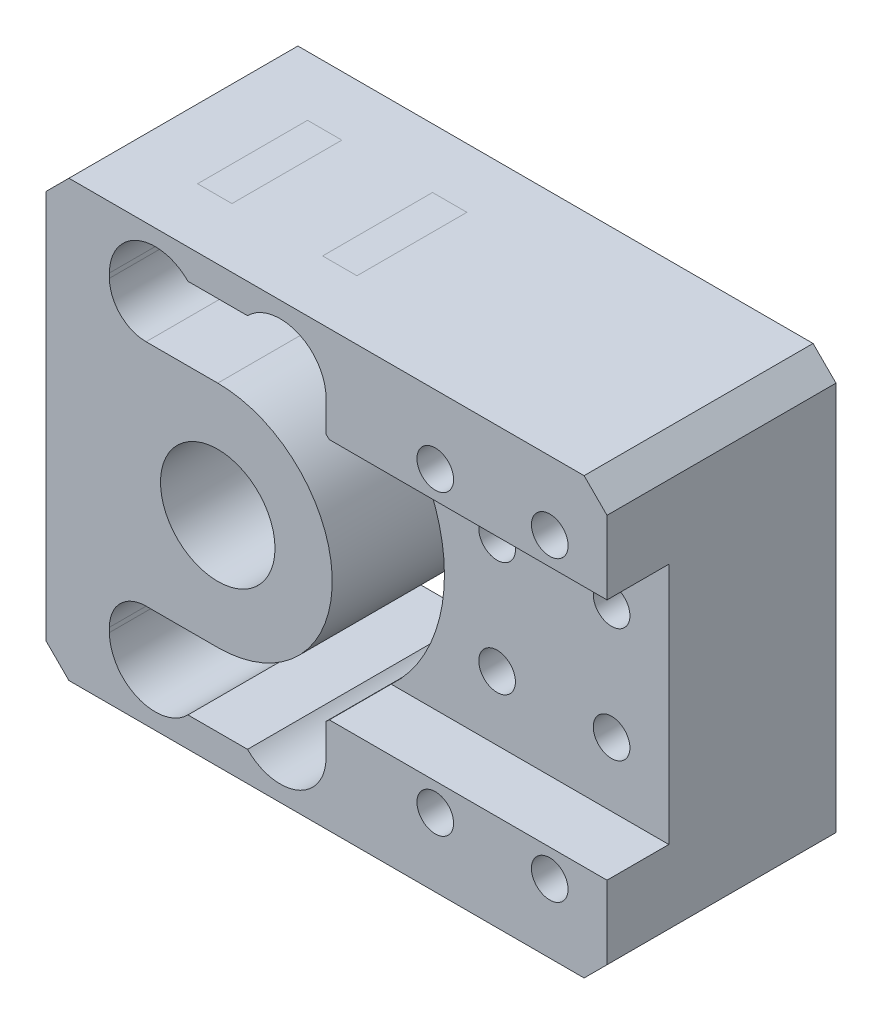
from build123d import *

# Parameters (mm, degrees)
SKETCH1_W                = 15
SKETCH1_H                = 19
BOSS_EXTRUDE1_DEPTH      = 5
BOSS_EXTRUDE1_DEPTH_BACK = 5
CUT_EXTRUDE1_START       = -6
SKETCH2_R                = 2
CUT_EXTRUDE1_DEPTH       = 16
SKETCH5_R                = 2
CUT_EXTRUDE4_DEPTH       = 17
CUT_EXTRUDE4_DEPTH_BACK  = 17
SKETCH6_R                = 2
CUT_EXTRUDE5_DEPTH       = 17
CUT_EXTRUDE5_DEPTH_BACK  = 17
SKETCH10_W               = 9.46
SKETCH10_H               = 13.6
CUT_EXTRUDE6_DEPTH       = 6
CUT_EXTRUDE6_DEPTH_BACK  = 6
BOSS_EXTRUDE2_START      = -5
SKETCH7_R                = 5
SKETCH7_R_2              = 2.5
BOSS_EXTRUDE2_DEPTH      = 10
BOSS_EXTRUDE3_DEPTH      = 5
FILLET1_R                = 1.6
SKETCH11_W               = 12.27
SKETCH11_H               = 19
BOSS_EXTRUDE4_DEPTH      = 10
CHAMFER1_SIZE            = 1
SKETCH16_W               = 5.80562201
SKETCH16_H               = 3.2
CUT_EXTRUDE8_DEPTH       = 11.5
CUT_EXTRUDE9_DEPTH       = 11.5
CUT_EXTRUDE10_DEPTH      = 2.7
TROU_TARAUD_M21_D        = 1.6
TROU_TARAUD_M2_51_D      = 2.05
TROU_TARAUD_M2_51_DEPTH  = 8.25
TROU_TARAUD_M2_51_TIP    = 0.615882135


with BuildPart() as part:
    # Sketch1 → Boss-Extrude1 (new body, two sides)
    with BuildSketch(Plane.XY) as boss_extrude1_sk:
        Rectangle(SKETCH1_W, SKETCH1_H)
    extrude(amount=BOSS_EXTRUDE1_DEPTH)
    extrude(boss_extrude1_sk.sketch, amount=-BOSS_EXTRUDE1_DEPTH_BACK)

    # Sketch2 → Cut-Extrude1 (cut)
    with BuildSketch(Plane.XY.offset(CUT_EXTRUDE1_START)):
        with Locations((-2.73, 6.8)):
            Circle(SKETCH2_R)
    cut_extrude1 = extrude(amount=CUT_EXTRUDE1_DEPTH, mode=Mode.SUBTRACT)

    # Mirror3: Cut-Extrude1 across plane
    add(cut_extrude1.mirror(Plane.ZX), mode=Mode.SUBTRACT)

    # Sketch5 → Cut-Extrude4 (cut, two sides)
    with BuildSketch(Plane.XY) as cut_extrude4_sk:
        with Locations((2.73, 6.8)):
            Circle(SKETCH5_R)
    extrude(amount=CUT_EXTRUDE4_DEPTH, mode=Mode.SUBTRACT)
    extrude(cut_extrude4_sk.sketch, amount=-CUT_EXTRUDE4_DEPTH_BACK, mode=Mode.SUBTRACT)

    # Sketch6 → Cut-Extrude5 (cut, two sides)
    with BuildSketch(Plane.XY) as cut_extrude5_sk:
        with Locations((2.73, -6.8)):
            Circle(SKETCH6_R)
    extrude(amount=CUT_EXTRUDE5_DEPTH, mode=Mode.SUBTRACT)
    extrude(cut_extrude5_sk.sketch, amount=-CUT_EXTRUDE5_DEPTH_BACK, mode=Mode.SUBTRACT)

    # Sketch10 → Cut-Extrude6 (cut, two sides)
    with BuildSketch(Plane.XY) as cut_extrude6_sk:
        Rectangle(SKETCH10_W, SKETCH10_H)
    extrude(amount=CUT_EXTRUDE6_DEPTH, mode=Mode.SUBTRACT)
    extrude(cut_extrude6_sk.sketch, amount=-CUT_EXTRUDE6_DEPTH_BACK, mode=Mode.SUBTRACT)



with BuildPart() as body_2:
    # Sketch7 → Boss-Extrude2 (new body)
    with BuildSketch(Plane.XY.offset(BOSS_EXTRUDE2_START)):
        Circle(SKETCH7_R)
        Circle(SKETCH7_R_2, mode=Mode.SUBTRACT)
    extrude(amount=BOSS_EXTRUDE2_DEPTH)


with BuildPart() as part_1:
    add(part.part)

    add(body_2.part)  # Boss-Extrude3 merges body 2
    # Sketch8 → Boss-Extrude3 (add, symmetric)
    with BuildSketch(Plane.XY):
        Polygon((0, 5), (-7.5, 5), (-7.5, 0), (-5, 0), align=None)
    boss_extrude3 = extrude(amount=BOSS_EXTRUDE3_DEPTH, both=True)

    # Mirror7: Boss-Extrude3 across plane
    add(boss_extrude3.mirror(Plane.ZX))

    # Fillet1
    fillet1_edges = [part_1.edges().sort_by_distance(p)[0] for p in [
        (-4.73, -5, 0),
        (-4.73, 5, 0),
    ]]
    fillet(fillet1_edges, radius=FILLET1_R)

    # Sketch11 → Boss-Extrude4 (add)
    with BuildSketch(Plane.XY.offset(5)):
        with Locations((10.865, 0)):
            Rectangle(SKETCH11_W, SKETCH11_H)
    extrude(amount=-BOSS_EXTRUDE4_DEPTH)

    # Chamfer1
    chamfer1_edges = [part_1.edges().sort_by_distance(p)[0] for p in [
        (17, 9.5, 0),
        (17, -9.5, 0),
        (-7.5, 9.5, 0),
        (-7.5, -9.5, 0),
    ]]
    chamfer(chamfer1_edges, length=CHAMFER1_SIZE)

    # Sketch16 → Cut-Extrude8 (cut)
    with BuildSketch(Plane.XY.offset(5)):
        with Locations((-0.227188995, 6.6)):
            Rectangle(SKETCH16_W, SKETCH16_H)
    cut_extrude8 = extrude(amount=-CUT_EXTRUDE8_DEPTH, mode=Mode.SUBTRACT)

    # Mirror8: Cut-Extrude8 across plane
    add(cut_extrude8.mirror(Plane.ZX), mode=Mode.SUBTRACT)

    # Sketch17 → Cut-Extrude9 (cut)
    with BuildSketch(Plane.XY.offset(5)):
        with BuildLine():
            ThreePointArc((2.678170763, -4.222250746), (5, 0), (2.678170763, 4.222250746))
            ThreePointArc((2.678170763, 4.222250746), (2.338473166, 5.740343478), (3.856565898, 6.080041075))
            ThreePointArc((3.856565898, 6.080041075), (7.2, 0), (3.856565898, -6.080041075))
            ThreePointArc((3.856565898, -6.080041075), (2.338473166, -5.740343478), (2.678170763, -4.222250746))
        make_face()
    extrude(amount=-CUT_EXTRUDE9_DEPTH, mode=Mode.SUBTRACT)

    # Sketch20 → Cut-Extrude10 (cut)
    with BuildSketch(Plane.XY.offset(5)):
        with BuildLine():
            Line((17, 5.3), (4.73, 5.3))
            ThreePointArc((4.73, 5.3), (7.103724375, 0), (4.73, -5.3))
            Line((4.73, -5.3), (17, -5.3))
            Line((17, -5.3), (17, 5.3))
        make_face()
    extrude(amount=-CUT_EXTRUDE10_DEPTH, mode=Mode.SUBTRACT)

    # Trou taraud_ M21 (through all)
    with Locations(Plane.XY.offset(5)):
        with Locations((14.5, 2.5), (14.5, -2.5), (9.5, 2.5), (9.5, -2.5), (9.5, 6.5), (14.5, 6.5), (9.5, -6.5), (14.5, -6.5)):
            Hole(TROU_TARAUD_M21_D / 2)

    # Trou taraud_ M2.51
    with Locations(Plane.ZY.offset(7.5)):
        with Locations((0, 0)):
            Hole(TROU_TARAUD_M2_51_D / 2, depth=TROU_TARAUD_M2_51_DEPTH)
            with Locations((0, 0, -(TROU_TARAUD_M2_51_DEPTH + TROU_TARAUD_M2_51_TIP / 2))):  # 118° drill point
                Cone(0, TROU_TARAUD_M2_51_D / 2, TROU_TARAUD_M2_51_TIP, mode=Mode.SUBTRACT)


solid = part_1.part
